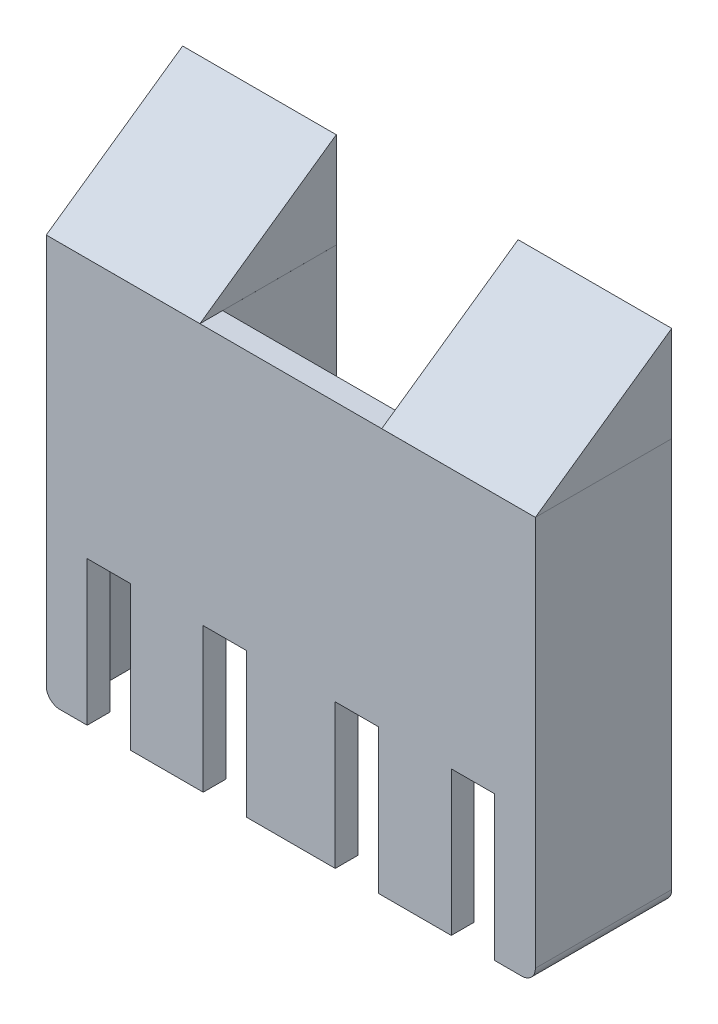
from build123d import *

# Parameters (mm, degrees)
SKETCH4_W                = 101.6
SKETCH4_H                = 88.9
BOSS_EXTRUDE3_DEPTH      = 30
SKETCH7_W                = 9.5
SKETCH7_H                = 31.75
CUT_EXTRUDE5_DEPTH       = 72.982237392
CUT_EXTRUDE5_DEPTH_BACK  = 72.982237392
CUT_EXTRUDE6_DEPTH       = 74.86773653
CUT_EXTRUDE6_DEPTH_BACK  = 25
BOSS_EXTRUDE4_DEPTH      = 30
BOSS_EXTRUDE6_DEPTH      = 107.6
SKETCH11_W               = 40
SKETCH11_H               = 21.008754769
CUT_EXTRUDE10_DEPTH      = 90.884862885
CUT_EXTRUDE10_DEPTH_BACK = 90.884862885


with BuildPart() as part:
    # Sketch4 → Boss-Extrude3 (new body)
    with BuildSketch(Plane.XY):
        Rectangle(SKETCH4_W, SKETCH4_H)
    extrude(amount=BOSS_EXTRUDE3_DEPTH)

    # Sketch7 → Cut-Extrude5 (cut, two sides)
    with BuildSketch(Plane(origin=(0, 0, 25), x_dir=(-1, 0, 0), z_dir=(0, 0, -1))) as cut_extrude5_sk:
        with Locations((40.05, -28.575)):
            Rectangle(SKETCH7_W, SKETCH7_H)
        with Locations((-40.05, -28.575)):
            Rectangle(SKETCH7_W, SKETCH7_H)
        with Locations((-14.52, -28.575)):
            Rectangle(SKETCH7_W, SKETCH7_H)
        with Locations((14.52, -28.575)):
            Rectangle(SKETCH7_W, SKETCH7_H)
    extrude(amount=CUT_EXTRUDE5_DEPTH, mode=Mode.SUBTRACT)
    extrude(cut_extrude5_sk.sketch, amount=-CUT_EXTRUDE5_DEPTH_BACK, mode=Mode.SUBTRACT)

    # Sketch8 → Cut-Extrude6 (cut, two sides)
    with BuildSketch(Plane(origin=(0, 0, 0), x_dir=(-1, 0, 0), z_dir=(0, 0, -1))) as cut_extrude6_sk:
        with BuildLine():
            Line((-50.8, -44.45), (-44.820757692, -12.809842787))
            ThreePointArc((-44.820757692, -12.809842787), (-44.794045948, -12.701829407), (-44.755499814, -12.597452192))
            Line((-44.755499814, -12.597452192), (-20, 44.45))
            Line((-20, 44.45), (20, 44.45))
            Line((20, 44.45), (20, 18.313203436))
            ThreePointArc((20, 18.313203436), (21.141807012, 12.57295195), (24.393398282, 7.706601718))
            Line((24.393398282, 7.706601718), (44.581799029, -12.481799029))
            ThreePointArc((44.581799029, -12.481799029), (44.758860381, -12.721736983), (44.857300667, -13.00321603))
            Line((44.857300667, -13.00321603), (50.8, -44.45))
            Line((50.8, -44.45), (-50.8, -44.45))
        make_face()
    extrude(amount=CUT_EXTRUDE6_DEPTH, mode=Mode.SUBTRACT)
    extrude(cut_extrude6_sk.sketch, amount=-CUT_EXTRUDE6_DEPTH_BACK, mode=Mode.SUBTRACT)

    # Sketch9 → Boss-Extrude4 (add)
    with BuildSketch(Plane.XY.offset(30)):
        with BuildLine():
            Line((53.8, -41.452528622), (53.8, 44.452528622))
            Line((53.8, 44.452528622), (50.8, 44.452528622))
            Line((50.8, 44.452528622), (50.8, -44.452528622))
            ThreePointArc((50.8, -44.452528622), (52.921320344, -43.573848966), (53.8, -41.452528622))
        make_face()
        with BuildLine():
            Line((-53.8, -41.452528622), (-53.8, 44.452528622))
            Line((-53.8, 44.452528622), (-50.8, 44.45))
            Line((-50.8, 44.45), (-50.8, -44.452528622))
            ThreePointArc((-50.8, -44.452528622), (-52.921320344, -43.573848966), (-53.8, -41.452528622))
        make_face()
    extrude(amount=-BOSS_EXTRUDE4_DEPTH)


with BuildPart() as body_2:
    # Sketch10 → Boss-Extrude6 (new body)
    with BuildSketch(Plane.ZY.offset(53.8)):
        Polygon((0, 44.452528622), (0, 65.458754769), (30, 44.452528622), align=None)
    extrude(amount=-BOSS_EXTRUDE6_DEPTH)

    # Sketch11 → Cut-Extrude10 (cut, two sides)
    with BuildSketch(Plane(origin=(0, 0, 0), x_dir=(-1, 0, 0), z_dir=(0, 0, -1))) as cut_extrude10_sk:
        with Locations((0, 54.954377385)):
            Rectangle(SKETCH11_W, SKETCH11_H)
    extrude(amount=CUT_EXTRUDE10_DEPTH, mode=Mode.SUBTRACT)
    extrude(cut_extrude10_sk.sketch, amount=-CUT_EXTRUDE10_DEPTH_BACK, mode=Mode.SUBTRACT)


with BuildPart() as cut_extrude10_piece_1:
    # of the separate pieces the step leaves, piece 1, a body of its own (cut_extrude10_pieces)
    add(body_2.part.solids().sort_by_distance((20, 65.458754769, 0))[0])


with BuildPart() as cut_extrude10_piece_2:
    # of the separate pieces the step leaves, piece 2, a body of its own (cut_extrude10_pieces)
    add(body_2.part.solids().sort_by_distance((-53.8, 44.452528622, 0))[0])


solid = Compound([part.part, cut_extrude10_piece_1.part, cut_extrude10_piece_2.part])
